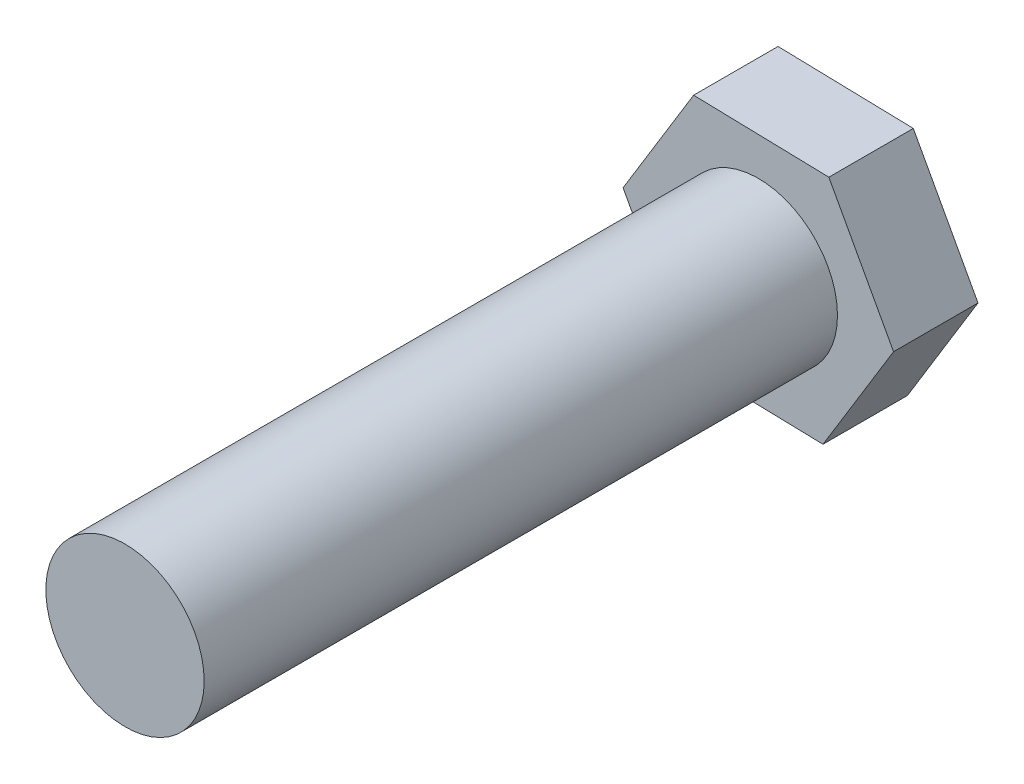
from build123d import *

# Parameters (mm, degrees)
EXTRUDE1_DEPTH    = 43.18
SKETCH2_OUTSIDE_W = 27.934
SKETCH2_OUTSIDE_H = 25.958
SKETCH2_OUTSIDE_R = 4.7625
EXTRUDE2_DEPTH    = 38.1


with BuildPart() as part:
    # Sketch1 → Extrude1 (new body)
    with BuildSketch(Plane.XY):
        Polygon((4.244335179, 6.944596596), (-3.892029482, 7.148000386), (-8.136364661, 0.203403789), (-4.244335179, -6.944596596), (3.892029482, -7.148000386), (8.136364661, -0.203403789), align=None)
    extrude(amount=EXTRUDE1_DEPTH)

    # Sketch2 outside → Extrude2 (cut)
    with BuildSketch(Plane.XY.offset(43.18)):
        Rectangle(SKETCH2_OUTSIDE_W, SKETCH2_OUTSIDE_H)
        Circle(SKETCH2_OUTSIDE_R, mode=Mode.SUBTRACT)
    extrude(amount=-EXTRUDE2_DEPTH, mode=Mode.SUBTRACT)


solid = part.part
